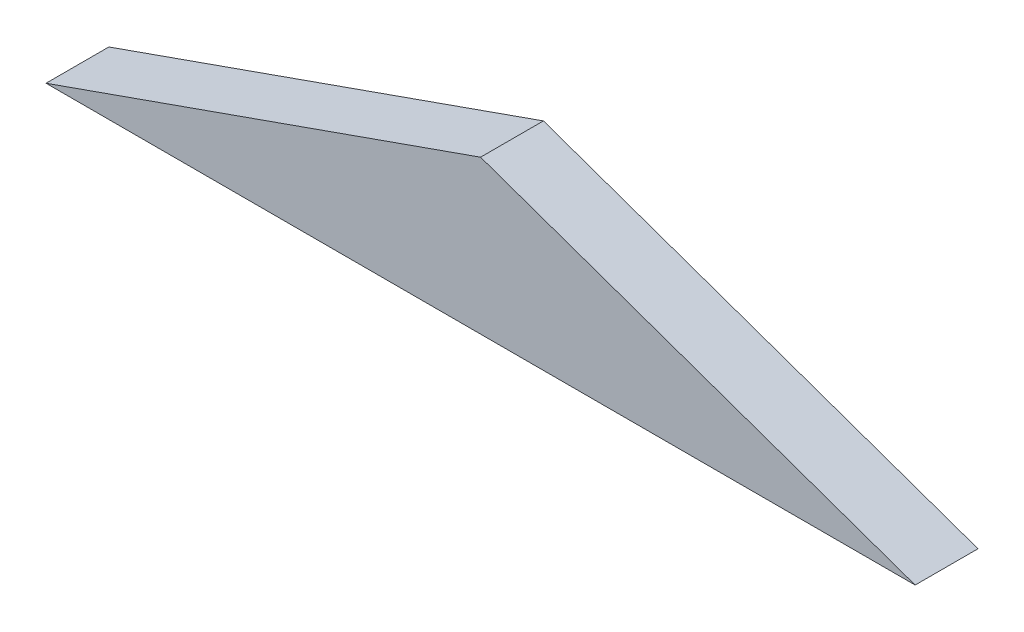
from build123d import *

# Parameters (mm, degrees)
BOSS_EXTRU_1_DEPTH = 3


with BuildPart() as part:
    # Esquisse1 → Boss.-Extru.1 (new body)
    with BuildSketch(Plane.XY):
        Polygon((0, 110), (-20.747770792, 102.683579622), (20.747770792, 102.683579622), align=None)
    extrude(amount=BOSS_EXTRU_1_DEPTH)


solid = part.part
